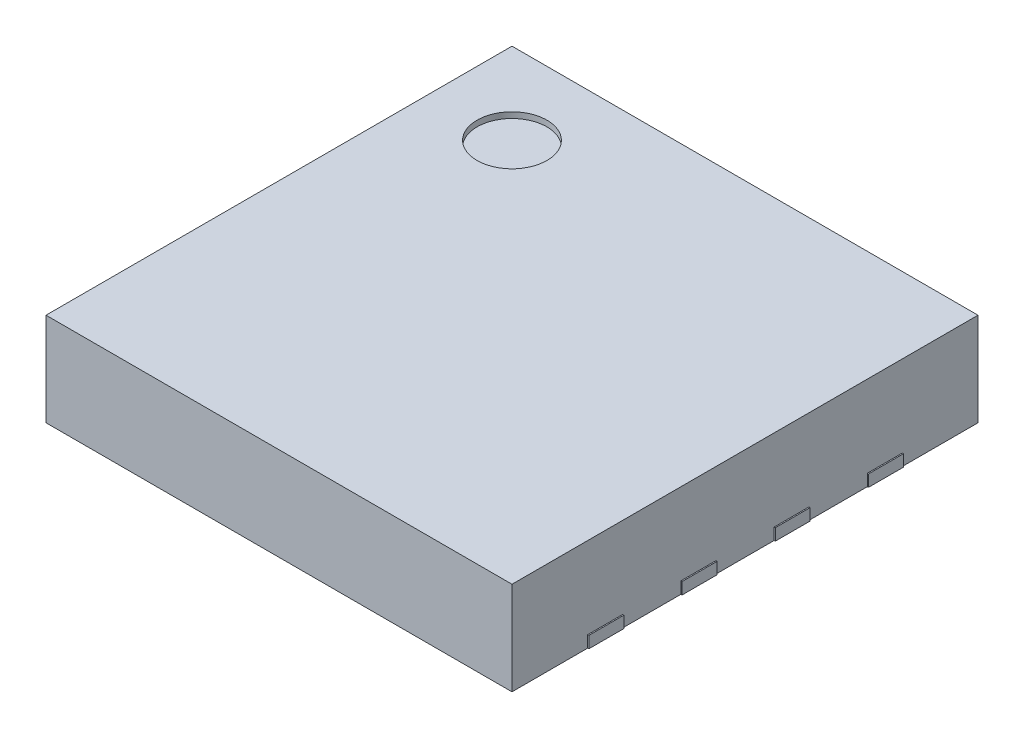
from build123d import *

# Parameters (mm, degrees)
SKETCH1_W           = 4
SKETCH1_H           = 4
BOSS_EXTRUDE1_DEPTH = 0.8
SKETCH2_W           = 0.3
SKETCH2_H           = 0.1
BOSS_EXTRUDE2_DEPTH = 0.01
SKETCH3_R           = 0.3
CUT_EXTRUDE1_DEPTH  = 0.05


with BuildPart() as part:
    # Sketch1 → Boss-Extrude1 (new body)
    with BuildSketch(Plane(origin=(0, 0, 0), x_dir=(1, 0, 0), z_dir=(0, 1, 0))):
        Rectangle(SKETCH1_W, SKETCH1_H)
    extrude(amount=BOSS_EXTRUDE1_DEPTH)

    # Sketch2 → Boss-Extrude2 (add)
    with BuildSketch(Plane(origin=(2, 0, 0), x_dir=(0, 0, -1), z_dir=(1, 0, 0))):
        with Locations((-1.2, 0.05)):
            Rectangle(SKETCH2_W, SKETCH2_H)
        with Locations((-0.4, 0.05)):
            Rectangle(SKETCH2_W, SKETCH2_H)
        with Locations((0.4, 0.05)):
            Rectangle(SKETCH2_W, SKETCH2_H)
        with Locations((1.2, 0.05)):
            Rectangle(SKETCH2_W, SKETCH2_H)
    boss_extrude2 = extrude(amount=BOSS_EXTRUDE2_DEPTH)

    # Mirror1: Boss-Extrude2 across plane
    add(boss_extrude2.mirror(Plane(origin=(0, 0, 0), x_dir=(0, 0, 1), z_dir=(1, 0, 0))))

    # Sketch3 → Cut-Extrude1 (cut)
    with BuildSketch(Plane(origin=(0, 0.8, 0), x_dir=(1, 0, 0), z_dir=(0, 1, 0))):
        with Locations((-1.3, 1.3)):
            Circle(SKETCH3_R)
    extrude(amount=-CUT_EXTRUDE1_DEPTH, mode=Mode.SUBTRACT)


solid = part.part
